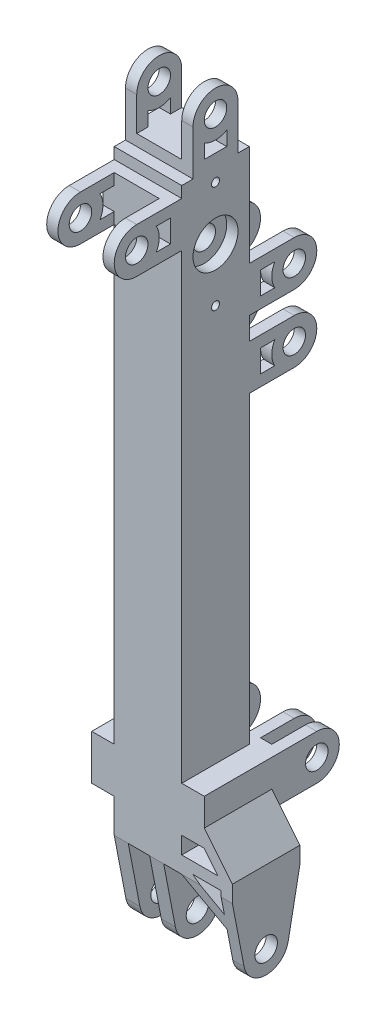
from build123d import *

# Parameters (mm, degrees)
SKETCH1_W                       = 19.05
SKETCH1_H                       = 19.05
BOSS_EXTRUDE1_DEPTH             = 190.5
CUT_EXTRUDE1_START              = 25.4
SKETCH2_W                       = 12.7
SKETCH2_H                       = 12.7
CUT_EXTRUDE1_DEPTH              = 120.65
CUT_EXTRUDE2_START              = 9.525
SKETCH4_R                       = 6.35
CUT_EXTRUDE2_DEPTH              = 3.175
CUT_EXTRUDE3_START              = -9.525
SKETCH4_3_R                     = 6.35
CUT_EXTRUDE3_DEPTH              = 3.175
SKETCH5_R                       = 3.175
CUT_EXTRUDE4_DEPTH              = 10.525
CUT_EXTRUDE4_DEPTH_BACK         = 10.525
F_4_40_TAPPED_HOLE1_D           = 2.2606
SKETCH8_R                       = 3.175
CUT_EXTRUDE5_DEPTH              = 10.525
CUT_EXTRUDE5_DEPTH_BACK         = 10.525
SKETCH9_W                       = 6.023585362
SKETCH9_H                       = 22.225
SKETCH9_W_2                     = 5.088914638
CUT_EXTRUDE6_DEPTH              = 10.525
CUT_EXTRUDE6_DEPTH_BACK         = 10.525
F_4_40_TAPPED_HOLE2_D           = 2.2606
F_4_40_TAPPED_HOLE2_DEPTH       = 3.96875
BOSS_EXTRUDE2_REACH             = 11.525
SKETCH12_R                      = 3.175
BOSS_EXTRUDE2_DIRECTION_2_REACH = 11.525
CUT_EXTRUDE7_REACH              = 189.325
SKETCH13_W                      = 12.7
SKETCH13_H                      = 15.875
BOSS_EXTRUDE3_REACH             = 11.525
SKETCH15_R                      = 3.175
BOSS_EXTRUDE3_DIRECTION_2_REACH = 11.525
CUT_EXTRUDE8_REACH              = 36.925
SKETCH16_W                      = 12.7
SKETCH16_H                      = 15.875
BOSS_EXTRUDE4_REACH             = 11.525
SKETCH17_R                      = 3.175
BOSS_EXTRUDE4_DIRECTION_2_REACH = 11.525
CUT_EXTRUDE9_REACH              = 163.925
SKETCH18_W                      = 12.7
SKETCH18_H                      = 15.875
BOSS_EXTRUDE5_REACH             = 11.525
SKETCH19_R                      = 3.175
BOSS_EXTRUDE5_DIRECTION_2_REACH = 11.525
CUT_EXTRUDE10_REACH             = 144.875
SKETCH20_W                      = 12.7
SKETCH20_H                      = 15.875
BOSS_EXTRUDE6_DEPTH             = 6.35
SKETCH25_R                      = 3.175
CUT_EXTRUDE11_DEPTH             = 16.875
CUT_EXTRUDE11_DEPTH_BACK        = 16.875
BOSS_EXTRUDE7_REACH             = 30.575
BOSS_EXTRUDE7_DIRECTION_2_REACH = 30.575
CUT_EXTRUDE13_REACH             = 41.688
SKETCH28_R                      = 3.175


with BuildPart() as part:
    # Sketch1 → Boss-Extrude1 (new body)
    with BuildSketch(Plane(origin=(0, 0, 0), x_dir=(1, 0, 0), z_dir=(0, 1, 0))):
        Rectangle(SKETCH1_W, SKETCH1_H)
    extrude(amount=BOSS_EXTRUDE1_DEPTH)

    # Sketch2 → Cut-Extrude1 (cut)
    with BuildSketch(Plane(origin=(0, 0, 0), x_dir=(1, 0, 0), z_dir=(0, 1, 0)).offset(CUT_EXTRUDE1_START)):
        Rectangle(SKETCH2_W, SKETCH2_H)
    extrude(amount=CUT_EXTRUDE1_DEPTH, mode=Mode.SUBTRACT)

    # Sketch4 → Cut-Extrude2 (cut)
    with BuildSketch(Plane(origin=(0, 0, 0), x_dir=(0, 0, -1), z_dir=(1, 0, 0)).offset(CUT_EXTRUDE2_START)):
        with Locations((0, 171.45)):
            Circle(SKETCH4_R)
    extrude(amount=-CUT_EXTRUDE2_DEPTH, mode=Mode.SUBTRACT)

    # Sketch4_3 → Cut-Extrude3 (cut)
    with BuildSketch(Plane(origin=(0, 0, 0), x_dir=(0, 0, -1), z_dir=(1, 0, 0)).offset(CUT_EXTRUDE3_START)):
        with Locations((0, 171.45)):
            Circle(SKETCH4_3_R)
    extrude(amount=CUT_EXTRUDE3_DEPTH, mode=Mode.SUBTRACT)

    # Sketch5 → Cut-Extrude4 (cut, two sides)
    with BuildSketch(Plane(origin=(0, 0, 0), x_dir=(0, 0, -1), z_dir=(1, 0, 0))) as cut_extrude4_sk:
        with Locations((0, 171.45)):
            Circle(SKETCH5_R)
    extrude(amount=CUT_EXTRUDE4_DEPTH, mode=Mode.SUBTRACT)
    extrude(cut_extrude4_sk.sketch, amount=-CUT_EXTRUDE4_DEPTH_BACK, mode=Mode.SUBTRACT)

    # 4-40 Tapped Hole1 (through all)
    with Locations(Plane(origin=(9.525, 0, 0), x_dir=(0, 0, -1), z_dir=(1, 0, 0))):
        with Locations((0, 186.53125), (0, 156.36875)):
            Hole(F_4_40_TAPPED_HOLE1_D / 2)

    # Sketch8 → Cut-Extrude5 (cut, two sides)
    with BuildSketch(Plane(origin=(0, 0, 0), x_dir=(0, 0, -1), z_dir=(1, 0, 0))) as cut_extrude5_sk:
        with BuildLine():
            Line((-9.525, 0), (0, 0))
            ThreePointArc((0, 0), (-4.043192745, 1.453563293), (-6.235350353, 5.148789788))
            Line((-6.235350353, 5.148789788), (-9.525, 22.225))
            Line((-9.525, 22.225), (-9.525, 0))
        make_face()
        with BuildLine():
            Line((9.525, 0), (9.525, 22.225))
            Line((9.525, 22.225), (6.235350353, 5.148789788))
            ThreePointArc((6.235350353, 5.148789788), (4.043192745, 1.453563293), (0, 0))
            Line((0, 0), (9.525, 0))
        make_face()
        with Locations((0, 6.35)):
            Circle(SKETCH8_R)
    extrude(amount=CUT_EXTRUDE5_DEPTH, mode=Mode.SUBTRACT)
    extrude(cut_extrude5_sk.sketch, amount=-CUT_EXTRUDE5_DEPTH_BACK, mode=Mode.SUBTRACT)

    # Sketch9 → Cut-Extrude6 (cut, two sides)
    with BuildSketch(Plane.XY) as cut_extrude6_sk:
        with Locations((-2.544457319, 11.1125)):
            Rectangle(SKETCH9_W, SKETCH9_H)
        with Locations((6.980542681, 11.1125)):
            Rectangle(SKETCH9_W_2, SKETCH9_H)
    extrude(amount=CUT_EXTRUDE6_DEPTH, mode=Mode.SUBTRACT)
    extrude(cut_extrude6_sk.sketch, amount=-CUT_EXTRUDE6_DEPTH_BACK, mode=Mode.SUBTRACT)

    # 4-40 Tapped Hole2
    with Locations(Plane.ZY.offset(9.525)):
        with Locations((0, 20.6375), (0, 14.2875)):
            Hole(F_4_40_TAPPED_HOLE2_D / 2, depth=F_4_40_TAPPED_HOLE2_DEPTH)

    # Boss-Extrude2: up to this face of the body (flat: up to its plane)
    boss_extrude2_end = Plane(part.part.faces().sort_by_distance((9.525, 103.50748805, 0))[0])
    # Sketch12 → Boss-Extrude2 (add, up to the picked face)
    with BuildSketch(Plane(origin=(0, 0, 0), x_dir=(0, 0, -1), z_dir=(1, 0, 0)), mode=Mode.PRIVATE) as boss_extrude2_sk1:
        with BuildLine():
            Line((-9.525, 187.325), (-9.525, 174.625))
            Line((-9.525, 174.625), (-22.225, 174.625))
            ThreePointArc((-22.225, 174.625), (-28.575, 180.975), (-22.225, 187.325))
            Line((-22.225, 187.325), (-9.525, 187.325))
        make_face()
        with Locations((-22.225, 180.975)):
            Circle(SKETCH12_R, mode=Mode.SUBTRACT)
        with BuildLine():
            Line((-12.7, 184.15), (-12.7, 177.8))
            Line((-12.7, 177.8), (-16.725738686, 177.8))
            ThreePointArc((-16.725738686, 177.8), (-15.875, 180.975), (-16.725738686, 184.15))
            Line((-16.725738686, 184.15), (-12.7, 184.15))
        make_face(mode=Mode.SUBTRACT)
    boss_extrude2_tool1 = split(extrude(boss_extrude2_sk1.sketch, amount=BOSS_EXTRUDE2_REACH, mode=Mode.PRIVATE), bisect_by=boss_extrude2_end, keep=Keep.BOTH, mode=Mode.PRIVATE)
    add(boss_extrude2_tool1.solids().sort_by_distance((0, 180.975, 18.233181))[0])

    # Boss-Extrude2 direction 2: up to this face of the body (flat: up to its plane)
    boss_extrude2_direction_2_end = Plane(part.part.faces().sort_by_distance((-9.525, 96.015325043, 0))[0])
    # Sketch12 → Boss-Extrude2 direction 2 (add, up to the picked face)
    with BuildSketch(Plane(origin=(0, 0, 0), x_dir=(0, 0, -1), z_dir=(1, 0, 0)), mode=Mode.PRIVATE) as boss_extrude2_direction_2_sk1:
        with BuildLine():
            Line((-9.525, 187.325), (-9.525, 174.625))
            Line((-9.525, 174.625), (-22.225, 174.625))
            ThreePointArc((-22.225, 174.625), (-28.575, 180.975), (-22.225, 187.325))
            Line((-22.225, 187.325), (-9.525, 187.325))
        make_face()
        with Locations((-22.225, 180.975)):
            Circle(SKETCH12_R, mode=Mode.SUBTRACT)
        with BuildLine():
            Line((-12.7, 184.15), (-12.7, 177.8))
            Line((-12.7, 177.8), (-16.725738686, 177.8))
            ThreePointArc((-16.725738686, 177.8), (-15.875, 180.975), (-16.725738686, 184.15))
            Line((-16.725738686, 184.15), (-12.7, 184.15))
        make_face(mode=Mode.SUBTRACT)
    boss_extrude2_direction_2_tool1 = split(extrude(boss_extrude2_direction_2_sk1.sketch, amount=-BOSS_EXTRUDE2_DIRECTION_2_REACH, mode=Mode.PRIVATE), bisect_by=boss_extrude2_direction_2_end, keep=Keep.BOTH, mode=Mode.PRIVATE)
    add(boss_extrude2_direction_2_tool1.solids().sort_by_distance((0, 180.975, 18.233181))[0])

    # Sketch13 → Cut-Extrude7 (cut, up to next)
    with BuildSketch(Plane(origin=(0, 187.325, 0), x_dir=(1, 0, 0), z_dir=(0, 1, 0)), mode=Mode.PRIVATE) as cut_extrude7_sk1:
        with Locations((0, -20.6375)):
            Rectangle(SKETCH13_W, SKETCH13_H)
    cut_extrude7_tool1 = extrude(cut_extrude7_sk1.sketch, amount=-CUT_EXTRUDE7_REACH, mode=Mode.PRIVATE) & part.part
    add(cut_extrude7_tool1.solids().sort_by_distance((0, 187.325, 20.6375))[0], mode=Mode.SUBTRACT)

    # Boss-Extrude3: up to this face of the body (flat: up to its plane)
    boss_extrude3_end = Plane(part.part.faces().sort_by_distance((9.525, 107.59470762, 0.961990564))[0])
    # Sketch15 → Boss-Extrude3 (add, up to the picked face)
    with BuildSketch(Plane(origin=(0, 0, 0), x_dir=(0, 0, -1), z_dir=(1, 0, 0)), mode=Mode.PRIVATE) as boss_extrude3_sk1:
        with BuildLine():
            Line((-6.35, 190.5), (6.35, 190.5))
            Line((6.35, 190.5), (6.35, 203.2))
            ThreePointArc((6.35, 203.2), (0, 209.55), (-6.35, 203.2))
            Line((-6.35, 203.2), (-6.35, 190.5))
        make_face()
        with Locations((0, 203.2)):
            Circle(SKETCH15_R, mode=Mode.SUBTRACT)
        with BuildLine():
            Line((-3.175, 193.675), (3.175, 193.675))
            Line((3.175, 193.675), (3.175, 197.700738686))
            ThreePointArc((3.175, 197.700738686), (0, 196.85), (-3.175, 197.700738686))
            Line((-3.175, 197.700738686), (-3.175, 193.675))
        make_face(mode=Mode.SUBTRACT)
    boss_extrude3_tool1 = split(extrude(boss_extrude3_sk1.sketch, amount=BOSS_EXTRUDE3_REACH, mode=Mode.PRIVATE), bisect_by=boss_extrude3_end, keep=Keep.BOTH, mode=Mode.PRIVATE)
    add(boss_extrude3_tool1.solids().sort_by_distance((0, 199.208181, 0))[0])

    # Boss-Extrude3 direction 2: up to this face of the body (flat: up to its plane)
    boss_extrude3_direction_2_end = Plane(part.part.faces().sort_by_distance((-9.525, 100.144279514, 0.886114213))[0])
    # Sketch15 → Boss-Extrude3 direction 2 (add, up to the picked face)
    with BuildSketch(Plane(origin=(0, 0, 0), x_dir=(0, 0, -1), z_dir=(1, 0, 0)), mode=Mode.PRIVATE) as boss_extrude3_direction_2_sk1:
        with BuildLine():
            Line((-6.35, 190.5), (6.35, 190.5))
            Line((6.35, 190.5), (6.35, 203.2))
            ThreePointArc((6.35, 203.2), (0, 209.55), (-6.35, 203.2))
            Line((-6.35, 203.2), (-6.35, 190.5))
        make_face()
        with Locations((0, 203.2)):
            Circle(SKETCH15_R, mode=Mode.SUBTRACT)
        with BuildLine():
            Line((-3.175, 193.675), (3.175, 193.675))
            Line((3.175, 193.675), (3.175, 197.700738686))
            ThreePointArc((3.175, 197.700738686), (0, 196.85), (-3.175, 197.700738686))
            Line((-3.175, 197.700738686), (-3.175, 193.675))
        make_face(mode=Mode.SUBTRACT)
    boss_extrude3_direction_2_tool1 = split(extrude(boss_extrude3_direction_2_sk1.sketch, amount=-BOSS_EXTRUDE3_DIRECTION_2_REACH, mode=Mode.PRIVATE), bisect_by=boss_extrude3_direction_2_end, keep=Keep.BOTH, mode=Mode.PRIVATE)
    add(boss_extrude3_direction_2_tool1.solids().sort_by_distance((0, 199.208181, 0))[0])

    # Sketch16 → Cut-Extrude8 (cut, up to next)
    with BuildSketch(Plane(origin=(0, 0, -6.35), x_dir=(-1, 0, 0), z_dir=(0, 0, -1)), mode=Mode.PRIVATE) as cut_extrude8_sk1:
        with Locations((0, 201.6125)):
            Rectangle(SKETCH16_W, SKETCH16_H)
    cut_extrude8_tool1 = extrude(cut_extrude8_sk1.sketch, amount=-CUT_EXTRUDE8_REACH, mode=Mode.PRIVATE) & part.part
    add(cut_extrude8_tool1.solids().sort_by_distance((0, 201.6125, -6.35))[0], mode=Mode.SUBTRACT)

    # Boss-Extrude4: up to this face of the body (flat: up to its plane)
    boss_extrude4_end = Plane(part.part.faces().sort_by_distance((9.525, 112.186033906, 0.913779178))[0])
    # Sketch17 → Boss-Extrude4 (add, up to the picked face)
    with BuildSketch(Plane(origin=(0, 0, 0), x_dir=(0, 0, -1), z_dir=(1, 0, 0)), mode=Mode.PRIVATE) as boss_extrude4_sk1:
        with BuildLine():
            Line((9.525, 161.925), (9.525, 149.225))
            Line((9.525, 149.225), (22.225, 149.225))
            ThreePointArc((22.225, 149.225), (28.575, 155.575), (22.225, 161.925))
            Line((22.225, 161.925), (9.525, 161.925))
        make_face()
        with Locations((22.225, 155.575)):
            Circle(SKETCH17_R, mode=Mode.SUBTRACT)
        with BuildLine():
            Line((12.7, 158.75), (12.7, 152.4))
            Line((12.7, 152.4), (16.725738686, 152.4))
            ThreePointArc((16.725738686, 152.4), (15.875, 155.575), (16.725738686, 158.75))
            Line((16.725738686, 158.75), (12.7, 158.75))
        make_face(mode=Mode.SUBTRACT)
    boss_extrude4_tool1 = split(extrude(boss_extrude4_sk1.sketch, amount=BOSS_EXTRUDE4_REACH, mode=Mode.PRIVATE), bisect_by=boss_extrude4_end, keep=Keep.BOTH, mode=Mode.PRIVATE)
    add(boss_extrude4_tool1.solids().sort_by_distance((0, 155.575, -18.233181))[0])

    # Boss-Extrude4 direction 2: up to this face of the body (flat: up to its plane)
    boss_extrude4_direction_2_end = Plane(part.part.faces().sort_by_distance((-9.525, 104.735553876, 0.845045838))[0])
    # Sketch17 → Boss-Extrude4 direction 2 (add, up to the picked face)
    with BuildSketch(Plane(origin=(0, 0, 0), x_dir=(0, 0, -1), z_dir=(1, 0, 0)), mode=Mode.PRIVATE) as boss_extrude4_direction_2_sk1:
        with BuildLine():
            Line((9.525, 161.925), (9.525, 149.225))
            Line((9.525, 149.225), (22.225, 149.225))
            ThreePointArc((22.225, 149.225), (28.575, 155.575), (22.225, 161.925))
            Line((22.225, 161.925), (9.525, 161.925))
        make_face()
        with Locations((22.225, 155.575)):
            Circle(SKETCH17_R, mode=Mode.SUBTRACT)
        with BuildLine():
            Line((12.7, 158.75), (12.7, 152.4))
            Line((12.7, 152.4), (16.725738686, 152.4))
            ThreePointArc((16.725738686, 152.4), (15.875, 155.575), (16.725738686, 158.75))
            Line((16.725738686, 158.75), (12.7, 158.75))
        make_face(mode=Mode.SUBTRACT)
    boss_extrude4_direction_2_tool1 = split(extrude(boss_extrude4_direction_2_sk1.sketch, amount=-BOSS_EXTRUDE4_DIRECTION_2_REACH, mode=Mode.PRIVATE), bisect_by=boss_extrude4_direction_2_end, keep=Keep.BOTH, mode=Mode.PRIVATE)
    add(boss_extrude4_direction_2_tool1.solids().sort_by_distance((0, 155.575, -18.233181))[0])

    # Sketch18 → Cut-Extrude9 (cut, up to next)
    with BuildSketch(Plane(origin=(0, 161.925, 0), x_dir=(1, 0, 0), z_dir=(0, 1, 0)), mode=Mode.PRIVATE) as cut_extrude9_sk1:
        with Locations((0, 20.6375)):
            Rectangle(SKETCH18_W, SKETCH18_H)
    cut_extrude9_tool1 = extrude(cut_extrude9_sk1.sketch, amount=-CUT_EXTRUDE9_REACH, mode=Mode.PRIVATE) & part.part
    add(cut_extrude9_tool1.solids().sort_by_distance((0, 161.925, -20.6375))[0], mode=Mode.SUBTRACT)

    # Boss-Extrude5: up to this face of the body (flat: up to its plane)
    boss_extrude5_end = Plane(part.part.faces().sort_by_distance((9.525, 114.256750758, 0))[0])
    # Sketch19 → Boss-Extrude5 (add, up to the picked face)
    with BuildSketch(Plane(origin=(0, 0, 0), x_dir=(0, 0, -1), z_dir=(1, 0, 0)), mode=Mode.PRIVATE) as boss_extrude5_sk1:
        with BuildLine():
            Line((9.525, 142.875), (9.525, 130.175))
            Line((9.525, 130.175), (22.225, 130.175))
            ThreePointArc((22.225, 130.175), (28.575, 136.525), (22.225, 142.875))
            Line((22.225, 142.875), (9.525, 142.875))
        make_face()
        with Locations((22.225, 136.525)):
            Circle(SKETCH19_R, mode=Mode.SUBTRACT)
        with BuildLine():
            Line((12.7, 139.7), (12.7, 133.35))
            Line((12.7, 133.35), (16.725738686, 133.35))
            ThreePointArc((16.725738686, 133.35), (15.875, 136.525), (16.725738686, 139.7))
            Line((16.725738686, 139.7), (12.7, 139.7))
        make_face(mode=Mode.SUBTRACT)
    boss_extrude5_tool1 = split(extrude(boss_extrude5_sk1.sketch, amount=BOSS_EXTRUDE5_REACH, mode=Mode.PRIVATE), bisect_by=boss_extrude5_end, keep=Keep.BOTH, mode=Mode.PRIVATE)
    add(boss_extrude5_tool1.solids().sort_by_distance((0, 136.525, -18.233181))[0])

    # Boss-Extrude5 direction 2: up to this face of the body (flat: up to its plane)
    boss_extrude5_direction_2_end = Plane(part.part.faces().sort_by_distance((-9.525, 106.987422564, 0))[0])
    # Sketch19 → Boss-Extrude5 direction 2 (add, up to the picked face)
    with BuildSketch(Plane(origin=(0, 0, 0), x_dir=(0, 0, -1), z_dir=(1, 0, 0)), mode=Mode.PRIVATE) as boss_extrude5_direction_2_sk1:
        with BuildLine():
            Line((9.525, 142.875), (9.525, 130.175))
            Line((9.525, 130.175), (22.225, 130.175))
            ThreePointArc((22.225, 130.175), (28.575, 136.525), (22.225, 142.875))
            Line((22.225, 142.875), (9.525, 142.875))
        make_face()
        with Locations((22.225, 136.525)):
            Circle(SKETCH19_R, mode=Mode.SUBTRACT)
        with BuildLine():
            Line((12.7, 139.7), (12.7, 133.35))
            Line((12.7, 133.35), (16.725738686, 133.35))
            ThreePointArc((16.725738686, 133.35), (15.875, 136.525), (16.725738686, 139.7))
            Line((16.725738686, 139.7), (12.7, 139.7))
        make_face(mode=Mode.SUBTRACT)
    boss_extrude5_direction_2_tool1 = split(extrude(boss_extrude5_direction_2_sk1.sketch, amount=-BOSS_EXTRUDE5_DIRECTION_2_REACH, mode=Mode.PRIVATE), bisect_by=boss_extrude5_direction_2_end, keep=Keep.BOTH, mode=Mode.PRIVATE)
    add(boss_extrude5_direction_2_tool1.solids().sort_by_distance((0, 136.525, -18.233181))[0])

    # Sketch20 → Cut-Extrude10 (cut, up to next)
    with BuildSketch(Plane(origin=(0, 142.875, 0), x_dir=(1, 0, 0), z_dir=(0, 1, 0)), mode=Mode.PRIVATE) as cut_extrude10_sk1:
        with Locations((0, 20.6375)):
            Rectangle(SKETCH20_W, SKETCH20_H)
    cut_extrude10_tool1 = extrude(cut_extrude10_sk1.sketch, amount=-CUT_EXTRUDE10_REACH, mode=Mode.PRIVATE) & part.part
    add(cut_extrude10_tool1.solids().sort_by_distance((0, 142.875, -20.6375))[0], mode=Mode.SUBTRACT)

    # Sketch24 → Boss-Extrude6 (add, symmetric)
    with BuildSketch(Plane(origin=(0, 38.1, 0), x_dir=(-1, 0, 0), z_dir=(0, -1, 0))):
        Polygon((15.875, -9.525), (15.875, 28.575), (12.7, 28.575), (12.7, 12.7), (9.525, 12.7), (9.525, 28.575), (6.35, 28.575), (6.35, 12.7), (-6.35, 12.7), (-6.35, 28.575), (-9.525, 28.575), (-9.525, 12.7), (-12.7, 12.7), (-12.7, 28.575), (-15.875, 28.575), (-15.875, -9.525), (-9.525, -9.525), (-9.525, 9.525), (9.525, 9.525), (9.525, -9.525), align=None)
    extrude(amount=BOSS_EXTRUDE6_DEPTH, both=True)

    # Sketch25 → Cut-Extrude11 (cut, two sides)
    with BuildSketch(Plane(origin=(0, 0, 0), x_dir=(0, 0, -1), z_dir=(1, 0, 0))) as cut_extrude11_sk:
        with BuildLine():
            Line((28.575, 44.45), (22.225, 44.45))
            ThreePointArc((22.225, 44.45), (26.715128061, 42.590128061), (28.575, 38.1))
            Line((28.575, 38.1), (28.575, 44.45))
        make_face()
        with BuildLine():
            Line((28.575, 31.75), (28.575, 38.1))
            ThreePointArc((28.575, 38.1), (26.715128061, 33.609871939), (22.225, 31.75))
            Line((22.225, 31.75), (28.575, 31.75))
        make_face()
        with Locations((22.225, 38.1)):
            Circle(SKETCH25_R)
    extrude(amount=CUT_EXTRUDE11_DEPTH, mode=Mode.SUBTRACT)
    extrude(cut_extrude11_sk.sketch, amount=-CUT_EXTRUDE11_DEPTH_BACK, mode=Mode.SUBTRACT)

    # Boss-Extrude7: up to this face of the body (flat: up to its plane)
    boss_extrude7_end = Plane(part.part.faces().sort_by_distance((0, 95.25, 9.525))[0])
    # Sketch23 → Boss-Extrude7 (add, up to the picked face)
    with BuildSketch(Plane.XY, mode=Mode.PRIVATE) as boss_extrude7_sk1:
        Polygon((20.6375, 13.470302553), (20.6375, 0), (23.8125, 0), (23.8125, 26.940605106), (15.875, 36.668046714), (15.875, 31.75), (15.790188085, 31.75), (19.714608658, 26.940605106), (9.525, 26.940605106), (9.525, 22.225), align=None)
        Polygon((20.6375, 17.512249787), (12.7, 23.765605106), (20.6375, 23.765605106), align=None, mode=Mode.SUBTRACT)
    boss_extrude7_tool1 = split(extrude(boss_extrude7_sk1.sketch, amount=BOSS_EXTRUDE7_REACH, mode=Mode.PRIVATE), bisect_by=boss_extrude7_end, keep=Keep.BOTH, mode=Mode.PRIVATE)
    add(boss_extrude7_tool1.solids().sort_by_distance((21.031033, 6.735151, 0))[0])

    # Boss-Extrude7 direction 2: up to this face of the body (flat: up to its plane)
    boss_extrude7_direction_2_end = Plane(part.part.faces().sort_by_distance((0, 26.9875, -9.525))[0])
    # Sketch23 → Boss-Extrude7 direction 2 (add, up to the picked face)
    with BuildSketch(Plane.XY, mode=Mode.PRIVATE) as boss_extrude7_direction_2_sk1:
        Polygon((20.6375, 13.470302553), (20.6375, 0), (23.8125, 0), (23.8125, 26.940605106), (15.875, 36.668046714), (15.875, 31.75), (15.790188085, 31.75), (19.714608658, 26.940605106), (9.525, 26.940605106), (9.525, 22.225), align=None)
        Polygon((20.6375, 17.512249787), (12.7, 23.765605106), (20.6375, 23.765605106), align=None, mode=Mode.SUBTRACT)
    boss_extrude7_direction_2_tool1 = split(extrude(boss_extrude7_direction_2_sk1.sketch, amount=-BOSS_EXTRUDE7_DIRECTION_2_REACH, mode=Mode.PRIVATE), bisect_by=boss_extrude7_direction_2_end, keep=Keep.BOTH, mode=Mode.PRIVATE)
    add(boss_extrude7_direction_2_tool1.solids().sort_by_distance((21.031033, 6.735151, 0))[0])

    # Sketch28 → Cut-Extrude13 (cut, up to next)
    with BuildSketch(Plane(origin=(23.8125, 0, 0), x_dir=(0, 0, -1), z_dir=(1, 0, 0)), mode=Mode.PRIVATE) as cut_extrude13_sk1:
        with BuildLine():
            Line((9.525, 13.470302553), (9.525, 22.225))
            Line((9.525, 22.225), (6.235350353, 5.148789788))
            ThreePointArc((6.235350353, 5.148789788), (4.043192739, 1.453563288), (-1.6e-08, 0))
            Line((-1.6e-08, 0), (9.525, 0))
            Line((9.525, 0), (9.525, 13.470302553))
        make_face()
    cut_extrude13_tool1 = extrude(cut_extrude13_sk1.sketch, amount=-CUT_EXTRUDE13_REACH, mode=Mode.PRIVATE) & part.part
    add(cut_extrude13_tool1.solids().sort_by_distance((23.8125, 6.760647, -7.708492))[0], mode=Mode.SUBTRACT)
    # Sketch28 → Cut-Extrude13 (cut, up to next)
    with BuildSketch(Plane(origin=(23.8125, 0, 0), x_dir=(0, 0, -1), z_dir=(1, 0, 0)), mode=Mode.PRIVATE) as cut_extrude13_sk2:
        with BuildLine():
            Line((-9.525, 0), (-1.6e-08, 0))
            ThreePointArc((-1.6e-08, 0), (-4.043192752, 1.453563298), (-6.235350353, 5.148789788))
            Line((-6.235350353, 5.148789788), (-9.525, 22.225))
            Line((-9.525, 22.225), (-9.525, 13.470302553))
            Line((-9.525, 13.470302553), (-9.525, 0))
        make_face()
    cut_extrude13_tool2 = extrude(cut_extrude13_sk2.sketch, amount=-CUT_EXTRUDE13_REACH, mode=Mode.PRIVATE) & part.part
    add(cut_extrude13_tool2.solids().sort_by_distance((23.8125, 6.760647, 7.708492))[0], mode=Mode.SUBTRACT)
    # Sketch28 → Cut-Extrude13 (cut, up to next)
    with BuildSketch(Plane(origin=(23.8125, 0, 0), x_dir=(0, 0, -1), z_dir=(1, 0, 0)), mode=Mode.PRIVATE) as cut_extrude13_sk3:
        with Locations((0, 6.35)):
            Circle(SKETCH28_R)
    cut_extrude13_tool3 = extrude(cut_extrude13_sk3.sketch, amount=-CUT_EXTRUDE13_REACH, mode=Mode.PRIVATE) & part.part
    add(cut_extrude13_tool3.solids().sort_by_distance((23.8125, 6.35, 0))[0], mode=Mode.SUBTRACT)


solid = part.part
